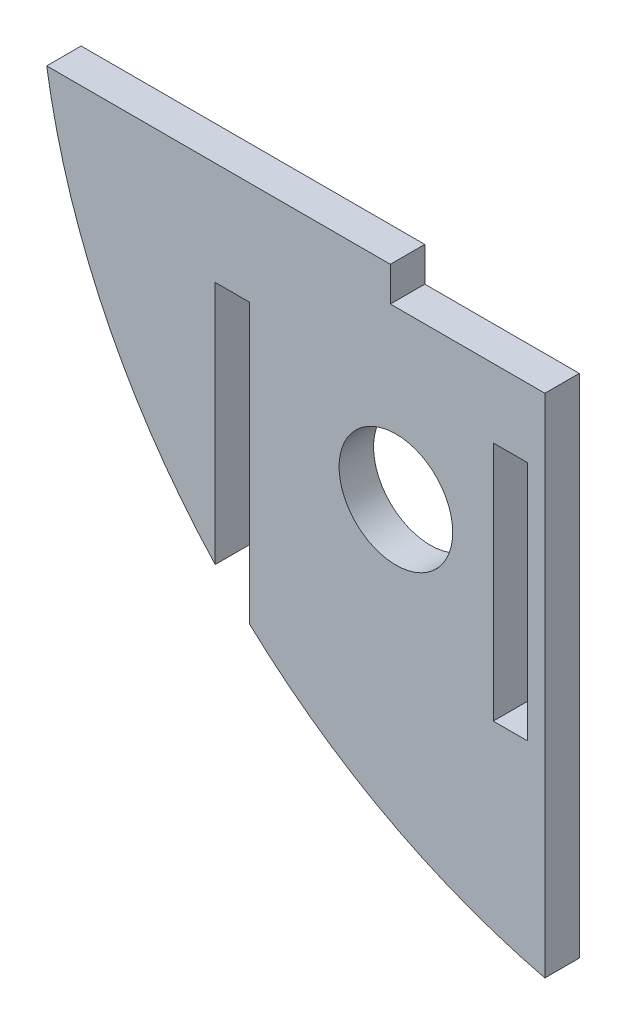
from build123d import *

# Parameters (mm, degrees)
SKETCH1_R           = 3.3
SKETCH1_W           = 2
SKETCH1_H           = 14
BOSS_EXTRUDE1_DEPTH = 2


with BuildPart() as part:
    # Sketch1 → Boss-Extrude1 (new body)
    with BuildSketch(Plane.XY):
        with BuildLine():
            Line((-19.253359056, 9.714066104), (-19.253359056, -6.489091482))
            ThreePointArc((-19.253359056, -6.489091482), (-11.269151238, -12.206183048), (-2.097048594, -15.714066104))
            Line((-2.097048594, -15.714066104), (-2.097048594, 13.714066104))
            Line((-2.097048594, 13.714066104), (-11.075689526, 13.714066104))
            Line((-11.075689526, 13.714066104), (-11.075689526, 15.714066104))
            Line((-11.075689526, 15.714066104), (-31.04567167, 15.714066104))
            ThreePointArc((-31.04567167, 15.714066104), (-27.656648188, 4.883682523), (-21.253359056, -4.485446411))
            Line((-21.253359056, -4.485446411), (-21.253359056, 9.714066104))
            Line((-21.253359056, 9.714066104), (-19.253359056, 9.714066104))
        make_face()
        with Locations((-10.753359056, 4.036396574)):
            Circle(SKETCH1_R, mode=Mode.SUBTRACT)
        with Locations((-4.097048594, 2.714066104)):
            Rectangle(SKETCH1_W, SKETCH1_H, mode=Mode.SUBTRACT)
    extrude(amount=BOSS_EXTRUDE1_DEPTH)


solid = part.part
